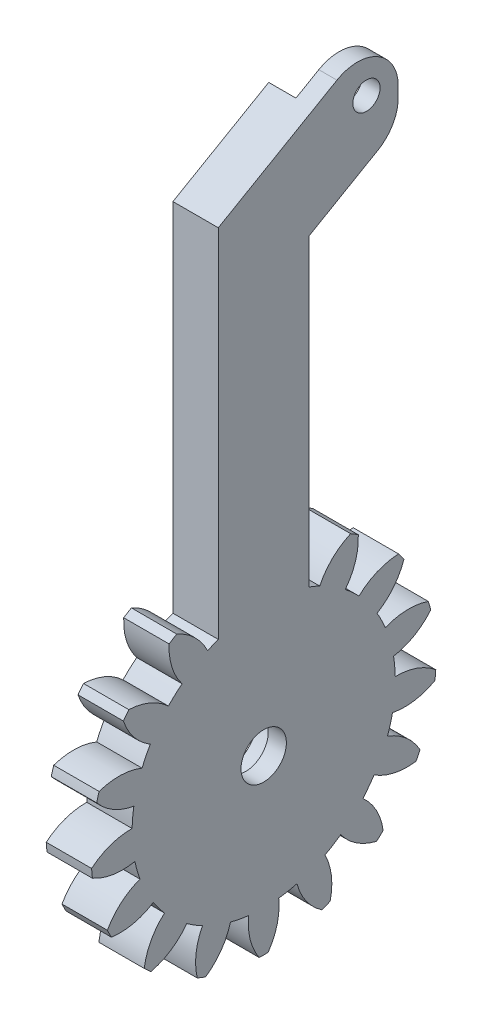
from build123d import *

# Parameters (mm, degrees)
BASPROSKE_W             = 10
BASPROSKE_H             = 19
TOOTHCUT_DEPTH          = 29.670542374
TEETHCUTS_COUNT         = 17
TEETHCUTS_ANGLE         = 338.823529412
BORSKE_R                = 2.5
BORE_DEPTH              = 50.0018796
CUT_EXTRUDE1_DEPTH      = 20
CUT_EXTRUDE1_DEPTH_BACK = 20
SKETCH1_W               = 10
SKETCH1_H               = 40
BOSS_EXTRUDE1_DEPTH     = 5
CUT_EXTRUDE2_START      = -3
SKETCH5_R               = 4.75
SKETCH5_R_2             = 2.5
CUT_EXTRUDE2_DEPTH      = 3
SKETCH6_R               = 1.5
CUT_EXTRUDE3_DEPTH      = 68.251600881
CUT_EXTRUDE4_DEPTH      = 3
FILLET1_R               = 4.5
FILLET2_R               = 4.5


with BuildPart() as part:
    # BasProSke → Base-Revolve (revolve)
    with BuildSketch(Plane(origin=(0, 0, 0), x_dir=(1, 0, 0), z_dir=(0, 1, 0))):
        with Locations((5, 9.5)):
            Rectangle(BASPROSKE_W, BASPROSKE_H)
    revolve(axis=Axis((-10, 0, 0), (1, 0, 0)))

    # TooCutSke → ToothCut (cut, through all)
    with BuildSketch(Plane(origin=(0, 0, 0), x_dir=(0, 0, -1), z_dir=(1, 0, 0))):
        with BuildLine():
            ThreePointArc((1.020352389, 14.463052306), (0, 14.499), (-1.020352389, 14.463052306))
            ThreePointArc((-1.020352389, 14.463052306), (-1.632621885, 16.804485203), (-3.026143023, 18.783192049))
            ThreePointArc((-3.026143023, 18.783192049), (0, 19.0254), (3.026143023, 18.783192049))
            ThreePointArc((3.026143023, 18.783192049), (1.632621885, 16.804485203), (1.020352389, 14.463052306))
        make_face()
    toothcut = extrude(amount=TOOTHCUT_DEPTH, mode=Mode.SUBTRACT)

    # TeethCuts: ToothCut ×17 about axis
    teethcuts_axis = Axis((-10, 0, 0), (1, 0, 0))
    for i in range(1, TEETHCUTS_COUNT):
        add(toothcut.rotate(teethcuts_axis, i * TEETHCUTS_ANGLE / (TEETHCUTS_COUNT - 1)), mode=Mode.SUBTRACT)

    # BorSke → Bore (cut, symmetric)
    with BuildSketch(Plane(origin=(0, 0, 0), x_dir=(0, 0, -1), z_dir=(1, 0, 0))):
        Circle(BORSKE_R)
    extrude(amount=BORE_DEPTH, both=True, mode=Mode.SUBTRACT)

    # Sketch1 → Cut-Extrude1 (cut, two sides: drawn at the far end of the back side and taken through both)
    with BuildSketch(Plane.XY.offset(-CUT_EXTRUDE1_DEPTH_BACK)):
        Rectangle(SKETCH1_W, SKETCH1_H)
    extrude(amount=CUT_EXTRUDE1_DEPTH + CUT_EXTRUDE1_DEPTH_BACK, mode=Mode.SUBTRACT)

    # Sketch4 → Boss-Extrude1 (add)
    with BuildSketch(Plane(origin=(10, 0, 0), x_dir=(0, 0, -1), z_dir=(1, 0, 0))):
        with BuildLine():
            Line((5, 0), (5, 47.113248654))
            Line((5, 47.113248654), (14.820508076, 52.783121635))
            Line((14.820508076, 52.783121635), (14.820508076, 64.330127019))
            Line((14.820508076, 64.330127019), (-5, 52.886751346))
            Line((-5, 52.886751346), (-5, 0))
            Line((-5, 0), (-2.5, 0))
            ThreePointArc((-2.5, 0), (0, 2.5), (2.5, 0))
            Line((2.5, 0), (5, 0))
        make_face()
    extrude(amount=-BOSS_EXTRUDE1_DEPTH)

    # Sketch5 → Cut-Extrude2 (cut)
    with BuildSketch(Plane.ZY.offset(-5).offset(CUT_EXTRUDE2_START)):
        Circle(SKETCH5_R)
        Circle(SKETCH5_R_2, mode=Mode.SUBTRACT)
    extrude(amount=CUT_EXTRUDE2_DEPTH, mode=Mode.SUBTRACT)

    # Sketch6 → Cut-Extrude3 (cut, through all)
    with BuildSketch(Plane.ZY.offset(-5)):
        with Locations((-11.320508076, 57.330127019)):
            Circle(SKETCH6_R)
    extrude(amount=-CUT_EXTRUDE3_DEPTH, mode=Mode.SUBTRACT)

    # Sketch7 → Cut-Extrude4 (cut)
    with BuildSketch(Plane.ZY.offset(-5)):
        with BuildLine():
            Line((-21.855234833, 56.484151118), (-14.320508076, 52.133974596))
            ThreePointArc((-14.320508076, 52.133974596), (-6.124355653, 54.330127019), (-8.320508076, 62.526279442))
            Line((-8.320508076, 62.526279442), (-15.855234833, 66.876455963))
            Line((-15.855234833, 66.876455963), (-21.855234833, 56.484151118))
        make_face()
    extrude(amount=-CUT_EXTRUDE4_DEPTH, mode=Mode.SUBTRACT)

    # Fillet1
    fillet1_edges = [part.edges().sort_by_distance(p)[0] for p in [
        (9, 52.783121635, -14.820508076),
        (9, 64.330127019, -14.820508076),
    ]]
    fillet(fillet1_edges, radius=FILLET1_R)

    # Fillet2
    fillet2_edges = [part.edges().sort_by_distance(p)[0] for p in [
        (6.5, 51.449252752, -12.5101794),
    ]]
    fillet(fillet2_edges, radius=FILLET2_R)


solid = part.part
